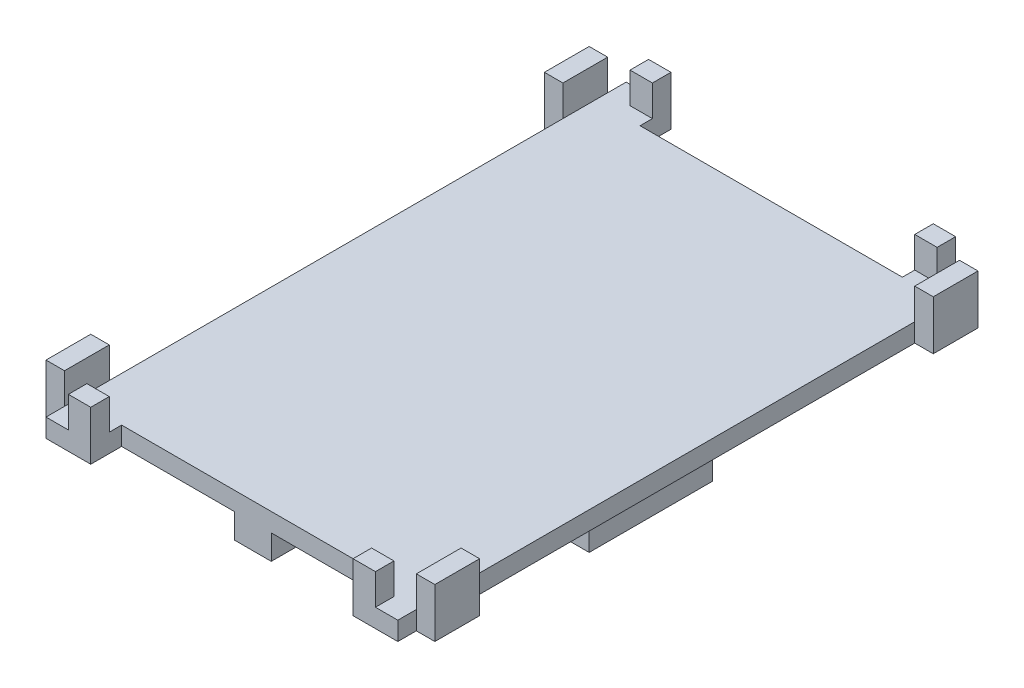
from build123d import *

# Parameters (mm, degrees)
BOSS_EXTRUDE1_DEPTH = 20
BOSS_EXTRUDE2_DEPTH = 3
SKETCH4_W           = 3
SKETCH4_H           = 7.25
BOSS_EXTRUDE3_DEPTH = 5
SKETCH5_W           = 3.625
SKETCH5_H           = 3
BOSS_EXTRUDE4_DEPTH = 5
SKETCH6_W           = 6
SKETCH6_H           = 84
BOSS_EXTRUDE5_DEPTH = 4


with BuildPart() as part:
    # Sketch2 → Boss-Extrude1 (new body)
    with BuildSketch(Plane.XY):
        Polygon((-17.6, 0), (-17.6, -1.1), (-14.5, -1.1), (-14.5, -5), (-22.5, -5), (-22.5, 0), (-22.5, 4), (22.5, 4), (22.5, -5), (14.5, -5), (14.5, -1.1), (17.6, -1.1), (17.6, 0), align=None)
    extrude(amount=BOSS_EXTRUDE1_DEPTH)

    # Sketch3 → Boss-Extrude2 (add)
    with BuildSketch(Plane(origin=(0, 4, 0), x_dir=(1, 0, 0), z_dir=(0, 1, 0))):
        Polygon((-21.25, -52), (21.25, -52), (21.25, -54), (21.25, -57), (28.5, -57), (28.5, -54), (31.5, -54), (31.5, -46.75), (28.5, -46.75), (28.5, 26.75), (31.5, 26.75), (31.5, 34), (28.5, 34), (28.5, 37), (21.25, 37), (21.25, 34), (21.25, 32), (-21.25, 32), (-21.25, 34), (-21.25, 37), (-28.5, 37), (-28.5, 34), (-31.5, 34), (-31.5, 26.75), (-28.5, 26.75), (-28.5, -46.75), (-31.5, -46.75), (-31.5, -54), (-28.5, -54), (-28.5, -57), (-21.25, -57), (-21.25, -54), align=None)
    extrude(amount=BOSS_EXTRUDE2_DEPTH)

    # Sketch4 → Boss-Extrude3 (add)
    with BuildSketch(Plane(origin=(0, 7, 0), x_dir=(1, 0, 0), z_dir=(0, 1, 0))):
        with Locations((-30, 30.375)):
            Rectangle(SKETCH4_W, SKETCH4_H)
        with Locations((30, 30.375)):
            Rectangle(SKETCH4_W, SKETCH4_H)
        with Locations((30, -50.375)):
            Rectangle(SKETCH4_W, SKETCH4_H)
        with Locations((-30, -50.375)):
            Rectangle(SKETCH4_W, SKETCH4_H)
    extrude(amount=BOSS_EXTRUDE3_DEPTH)

    # Sketch5 → Boss-Extrude4 (add)
    with BuildSketch(Plane(origin=(0, 7, 0), x_dir=(1, 0, 0), z_dir=(0, 1, 0))):
        with Locations((-23.0625, 35.5)):
            Rectangle(SKETCH5_W, SKETCH5_H)
        with Locations((23.0625, 35.5)):
            Rectangle(SKETCH5_W, SKETCH5_H)
        with Locations((23.0625, -55.5)):
            Rectangle(SKETCH5_W, SKETCH5_H)
        with Locations((-23.0625, -55.5)):
            Rectangle(SKETCH5_W, SKETCH5_H)
    extrude(amount=BOSS_EXTRUDE4_DEPTH)

    # Sketch6 → Boss-Extrude5 (add)
    with BuildSketch(Plane.XZ.offset(-4)):
        with Locations((0, 10)):
            Rectangle(SKETCH6_W, SKETCH6_H)
    extrude(amount=BOSS_EXTRUDE5_DEPTH)


solid = part.part
